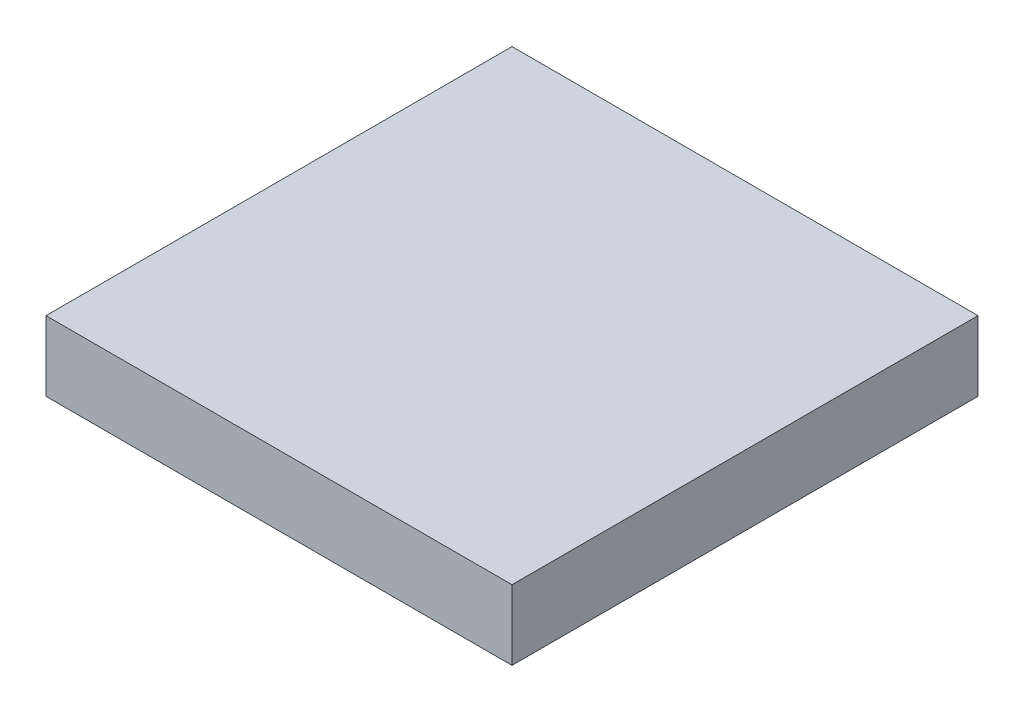
from build123d import *

# Parameters (mm, degrees)
SKETCH1_W           = 100
SKETCH1_H           = 100
BOSS_EXTRUDE1_DEPTH = 15


with BuildPart() as part:
    # Sketch1 → Boss-Extrude1 (new body)
    with BuildSketch(Plane(origin=(0, 0, 0), x_dir=(1, 0, 0), z_dir=(0, 1, 0))):
        with Locations((50, 50)):
            Rectangle(SKETCH1_W, SKETCH1_H)
    extrude(amount=BOSS_EXTRUDE1_DEPTH)


solid = part.part
